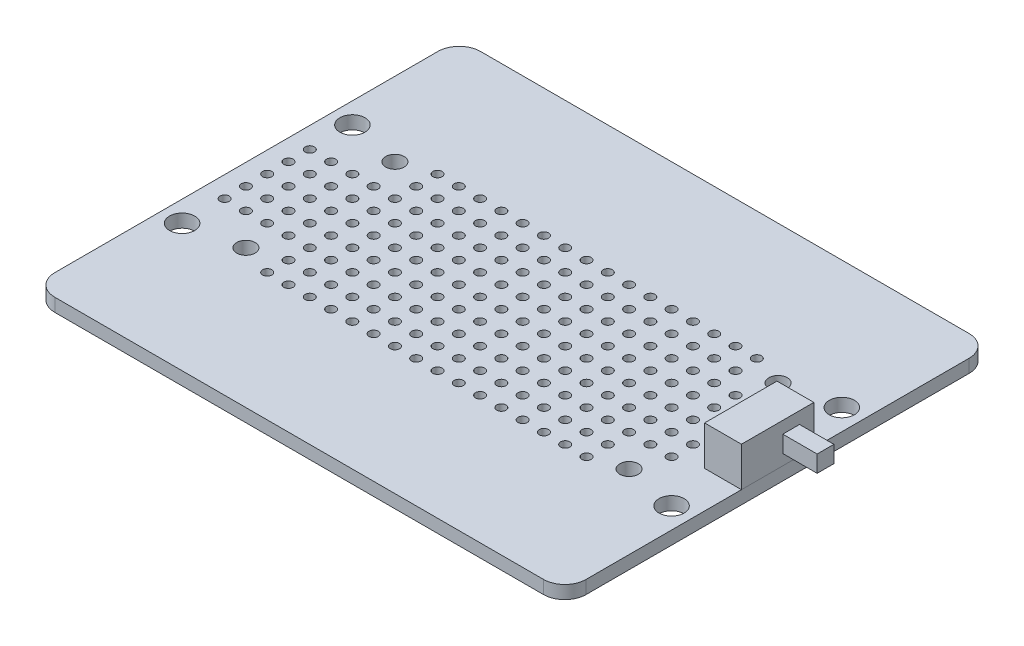
from build123d import *

# Parameters (mm, degrees)
SKETCH1_W           = 63.4
SKETCH1_H           = 50.8
SKETCH1_R           = 1.5
SKETCH1_R_2         = 1.1
BOSS_EXTRUDE1_DEPTH = 1.57
SKETCH9_R           = 0.55
CUT_EXTRUDE1_DEPTH  = 2.57
SKETCH7_W           = 4.4
SKETCH7_H           = 8.64
BOSS_EXTRUDE6_DEPTH = 4.7
SKETCH8_W           = 2
SKETCH8_H           = 2
BOSS_EXTRUDE7_DEPTH = 4.1
FILLET1_R           = 2.54


with BuildPart() as part:
    # Sketch1 → Boss-Extrude1 (new body)
    with BuildSketch(Plane(origin=(0, 0, 0), x_dir=(1, 0, 0), z_dir=(0, 1, 0))):
        Rectangle(SKETCH1_W, SKETCH1_H)
        with Locations((29.2, 10.16)):
            Circle(SKETCH1_R, mode=Mode.SUBTRACT)
        with Locations((29.2, -10.16)):
            Circle(SKETCH1_R, mode=Mode.SUBTRACT)
        with Locations((-29.2, 10.16)):
            Circle(SKETCH1_R, mode=Mode.SUBTRACT)
        with Locations((-29.2, -10.16)):
            Circle(SKETCH1_R, mode=Mode.SUBTRACT)
        with Locations((-22.86, 8.89)):
            Circle(SKETCH1_R_2, mode=Mode.SUBTRACT)
        with Locations((-22.86, -8.89)):
            Circle(SKETCH1_R_2, mode=Mode.SUBTRACT)
        with Locations((22.86, -8.89)):
            Circle(SKETCH1_R_2, mode=Mode.SUBTRACT)
        with Locations((22.86, 8.89)):
            Circle(SKETCH1_R_2, mode=Mode.SUBTRACT)
    extrude(amount=BOSS_EXTRUDE1_DEPTH)

    # Sketch9 → Cut-Extrude1 (cut, through all)
    with BuildSketch(Plane(origin=(0, 0, 0), x_dir=(1, 0, 0), z_dir=(0, 1, 0))):
        with Locations((-29.21, 10.16)):
            Circle(SKETCH9_R)
        with Locations((-19.05, 10.16)):
            Circle(SKETCH9_R)
        with Locations((-16.51, 10.16)):
            Circle(SKETCH9_R)
        with Locations((-13.97, 10.16)):
            Circle(SKETCH9_R)
        with Locations((-11.43, 10.16)):
            Circle(SKETCH9_R)
        with Locations((-8.89, 10.16)):
            Circle(SKETCH9_R)
        with Locations((-6.35, 10.16)):
            Circle(SKETCH9_R)
        with Locations((-3.81, 10.16)):
            Circle(SKETCH9_R)
        with Locations((-1.27, 10.16)):
            Circle(SKETCH9_R)
        with Locations((1.27, 10.16)):
            Circle(SKETCH9_R)
        with Locations((3.81, 10.16)):
            Circle(SKETCH9_R)
        with Locations((6.35, 10.16)):
            Circle(SKETCH9_R)
        with Locations((8.89, 10.16)):
            Circle(SKETCH9_R)
        with Locations((11.43, 10.16)):
            Circle(SKETCH9_R)
        with Locations((13.97, 10.16)):
            Circle(SKETCH9_R)
        with Locations((16.51, 10.16)):
            Circle(SKETCH9_R)
        with Locations((19.05, 10.16)):
            Circle(SKETCH9_R)
        with Locations((-19.05, 7.62)):
            Circle(SKETCH9_R)
        with Locations((-16.51, 7.62)):
            Circle(SKETCH9_R)
        with Locations((-13.97, 7.62)):
            Circle(SKETCH9_R)
        with Locations((-11.43, 7.62)):
            Circle(SKETCH9_R)
        with Locations((-8.89, 7.62)):
            Circle(SKETCH9_R)
        with Locations((-6.35, 7.62)):
            Circle(SKETCH9_R)
        with Locations((-3.81, 7.62)):
            Circle(SKETCH9_R)
        with Locations((-1.27, 7.62)):
            Circle(SKETCH9_R)
        with Locations((1.27, 7.62)):
            Circle(SKETCH9_R)
        with Locations((3.81, 7.62)):
            Circle(SKETCH9_R)
        with Locations((6.35, 7.62)):
            Circle(SKETCH9_R)
        with Locations((8.89, 7.62)):
            Circle(SKETCH9_R)
        with Locations((11.43, 7.62)):
            Circle(SKETCH9_R)
        with Locations((13.97, 7.62)):
            Circle(SKETCH9_R)
        with Locations((16.51, 7.62)):
            Circle(SKETCH9_R)
        with Locations((19.05, 7.62)):
            Circle(SKETCH9_R)
        with Locations((-26.67, 5.08)):
            Circle(SKETCH9_R)
        with Locations((-24.13, 5.08)):
            Circle(SKETCH9_R)
        with Locations((-21.59, 5.08)):
            Circle(SKETCH9_R)
        with Locations((-19.05, 5.08)):
            Circle(SKETCH9_R)
        with Locations((-16.51, 5.08)):
            Circle(SKETCH9_R)
        with Locations((-13.97, 5.08)):
            Circle(SKETCH9_R)
        with Locations((-11.43, 5.08)):
            Circle(SKETCH9_R)
        with Locations((-8.89, 5.08)):
            Circle(SKETCH9_R)
        with Locations((-6.35, 5.08)):
            Circle(SKETCH9_R)
        with Locations((-3.81, 5.08)):
            Circle(SKETCH9_R)
        with Locations((-1.27, 5.08)):
            Circle(SKETCH9_R)
        with Locations((1.27, 5.08)):
            Circle(SKETCH9_R)
        with Locations((3.81, 5.08)):
            Circle(SKETCH9_R)
        with Locations((6.35, 5.08)):
            Circle(SKETCH9_R)
        with Locations((8.89, 5.08)):
            Circle(SKETCH9_R)
        with Locations((11.43, 5.08)):
            Circle(SKETCH9_R)
        with Locations((13.97, 5.08)):
            Circle(SKETCH9_R)
        with Locations((16.51, 5.08)):
            Circle(SKETCH9_R)
        with Locations((19.05, 5.08)):
            Circle(SKETCH9_R)
        with Locations((21.59, 5.08)):
            Circle(SKETCH9_R)
        with Locations((24.13, 5.08)):
            Circle(SKETCH9_R)
        with Locations((-26.67, 2.54)):
            Circle(SKETCH9_R)
        with Locations((-24.13, 2.54)):
            Circle(SKETCH9_R)
        with Locations((-21.59, 2.54)):
            Circle(SKETCH9_R)
        with Locations((-19.05, 2.54)):
            Circle(SKETCH9_R)
        with Locations((-16.51, 2.54)):
            Circle(SKETCH9_R)
        with Locations((-13.97, 2.54)):
            Circle(SKETCH9_R)
        with Locations((-11.43, 2.54)):
            Circle(SKETCH9_R)
        with Locations((-8.89, 2.54)):
            Circle(SKETCH9_R)
        with Locations((-6.35, 2.54)):
            Circle(SKETCH9_R)
        with Locations((-3.81, 2.54)):
            Circle(SKETCH9_R)
        with Locations((-1.27, 2.54)):
            Circle(SKETCH9_R)
        with Locations((1.27, 2.54)):
            Circle(SKETCH9_R)
        with Locations((3.81, 2.54)):
            Circle(SKETCH9_R)
        with Locations((6.35, 2.54)):
            Circle(SKETCH9_R)
        with Locations((8.89, 2.54)):
            Circle(SKETCH9_R)
        with Locations((11.43, 2.54)):
            Circle(SKETCH9_R)
        with Locations((13.97, 2.54)):
            Circle(SKETCH9_R)
        with Locations((16.51, 2.54)):
            Circle(SKETCH9_R)
        with Locations((19.05, 2.54)):
            Circle(SKETCH9_R)
        with Locations((21.59, 2.54)):
            Circle(SKETCH9_R)
        with Locations((24.13, 2.54)):
            Circle(SKETCH9_R)
        with Locations((-26.67, 0)):
            Circle(SKETCH9_R)
        with Locations((-24.13, 0)):
            Circle(SKETCH9_R)
        with Locations((-21.59, 0)):
            Circle(SKETCH9_R)
        with Locations((-19.05, 0)):
            Circle(SKETCH9_R)
        with Locations((-16.51, 0)):
            Circle(SKETCH9_R)
        with Locations((-13.97, 0)):
            Circle(SKETCH9_R)
        with Locations((-11.43, 0)):
            Circle(SKETCH9_R)
        with Locations((-8.89, 0)):
            Circle(SKETCH9_R)
        with Locations((-6.35, 0)):
            Circle(SKETCH9_R)
        with Locations((-3.81, 0)):
            Circle(SKETCH9_R)
        with Locations((-1.27, 0)):
            Circle(SKETCH9_R)
        with Locations((1.27, 0)):
            Circle(SKETCH9_R)
        with Locations((3.81, 0)):
            Circle(SKETCH9_R)
        with Locations((6.35, 0)):
            Circle(SKETCH9_R)
        with Locations((8.89, 0)):
            Circle(SKETCH9_R)
        with Locations((11.43, 0)):
            Circle(SKETCH9_R)
        with Locations((13.97, 0)):
            Circle(SKETCH9_R)
        with Locations((16.51, 0)):
            Circle(SKETCH9_R)
        with Locations((19.05, 0)):
            Circle(SKETCH9_R)
        with Locations((21.59, 0)):
            Circle(SKETCH9_R)
        with Locations((24.13, 0)):
            Circle(SKETCH9_R)
        with Locations((-26.67, -2.54)):
            Circle(SKETCH9_R)
        with Locations((-24.13, -2.54)):
            Circle(SKETCH9_R)
        with Locations((-21.59, -2.54)):
            Circle(SKETCH9_R)
        with Locations((-19.05, -2.54)):
            Circle(SKETCH9_R)
        with Locations((-16.51, -2.54)):
            Circle(SKETCH9_R)
        with Locations((-13.97, -2.54)):
            Circle(SKETCH9_R)
        with Locations((-11.43, -2.54)):
            Circle(SKETCH9_R)
        with Locations((-8.89, -2.54)):
            Circle(SKETCH9_R)
        with Locations((-6.35, -2.54)):
            Circle(SKETCH9_R)
        with Locations((-3.81, -2.54)):
            Circle(SKETCH9_R)
        with Locations((-1.27, -2.54)):
            Circle(SKETCH9_R)
        with Locations((1.27, -2.54)):
            Circle(SKETCH9_R)
        with Locations((3.81, -2.54)):
            Circle(SKETCH9_R)
        with Locations((6.35, -2.54)):
            Circle(SKETCH9_R)
        with Locations((8.89, -2.54)):
            Circle(SKETCH9_R)
        with Locations((11.43, -2.54)):
            Circle(SKETCH9_R)
        with Locations((13.97, -2.54)):
            Circle(SKETCH9_R)
        with Locations((16.51, -2.54)):
            Circle(SKETCH9_R)
        with Locations((19.05, -2.54)):
            Circle(SKETCH9_R)
        with Locations((21.59, -2.54)):
            Circle(SKETCH9_R)
        with Locations((24.13, -2.54)):
            Circle(SKETCH9_R)
        with Locations((-26.67, -5.08)):
            Circle(SKETCH9_R)
        with Locations((-24.13, -5.08)):
            Circle(SKETCH9_R)
        with Locations((-21.59, -5.08)):
            Circle(SKETCH9_R)
        with Locations((-19.05, -5.08)):
            Circle(SKETCH9_R)
        with Locations((-16.51, -5.08)):
            Circle(SKETCH9_R)
        with Locations((-13.97, -5.08)):
            Circle(SKETCH9_R)
        with Locations((-11.43, -5.08)):
            Circle(SKETCH9_R)
        with Locations((-8.89, -5.08)):
            Circle(SKETCH9_R)
        with Locations((-6.35, -5.08)):
            Circle(SKETCH9_R)
        with Locations((-3.81, -5.08)):
            Circle(SKETCH9_R)
        with Locations((-1.27, -5.08)):
            Circle(SKETCH9_R)
        with Locations((1.27, -5.08)):
            Circle(SKETCH9_R)
        with Locations((3.81, -5.08)):
            Circle(SKETCH9_R)
        with Locations((6.35, -5.08)):
            Circle(SKETCH9_R)
        with Locations((8.89, -5.08)):
            Circle(SKETCH9_R)
        with Locations((11.43, -5.08)):
            Circle(SKETCH9_R)
        with Locations((13.97, -5.08)):
            Circle(SKETCH9_R)
        with Locations((16.51, -5.08)):
            Circle(SKETCH9_R)
        with Locations((19.05, -5.08)):
            Circle(SKETCH9_R)
        with Locations((21.59, -5.08)):
            Circle(SKETCH9_R)
        with Locations((24.13, -5.08)):
            Circle(SKETCH9_R)
        with Locations((-19.05, -7.62)):
            Circle(SKETCH9_R)
        with Locations((-16.51, -7.62)):
            Circle(SKETCH9_R)
        with Locations((-13.97, -7.62)):
            Circle(SKETCH9_R)
        with Locations((-11.43, -7.62)):
            Circle(SKETCH9_R)
        with Locations((-8.89, -7.62)):
            Circle(SKETCH9_R)
        with Locations((-6.35, -7.62)):
            Circle(SKETCH9_R)
        with Locations((-3.81, -7.62)):
            Circle(SKETCH9_R)
        with Locations((-1.27, -7.62)):
            Circle(SKETCH9_R)
        with Locations((1.27, -7.62)):
            Circle(SKETCH9_R)
        with Locations((3.81, -7.62)):
            Circle(SKETCH9_R)
        with Locations((6.35, -7.62)):
            Circle(SKETCH9_R)
        with Locations((8.89, -7.62)):
            Circle(SKETCH9_R)
        with Locations((11.43, -7.62)):
            Circle(SKETCH9_R)
        with Locations((13.97, -7.62)):
            Circle(SKETCH9_R)
        with Locations((16.51, -7.62)):
            Circle(SKETCH9_R)
        with Locations((19.05, -7.62)):
            Circle(SKETCH9_R)
        with Locations((-19.05, -10.16)):
            Circle(SKETCH9_R)
        with Locations((-16.51, -10.16)):
            Circle(SKETCH9_R)
        with Locations((-13.97, -10.16)):
            Circle(SKETCH9_R)
        with Locations((-11.43, -10.16)):
            Circle(SKETCH9_R)
        with Locations((-8.89, -10.16)):
            Circle(SKETCH9_R)
        with Locations((-6.35, -10.16)):
            Circle(SKETCH9_R)
        with Locations((-3.81, -10.16)):
            Circle(SKETCH9_R)
        with Locations((-1.27, -10.16)):
            Circle(SKETCH9_R)
        with Locations((1.27, -10.16)):
            Circle(SKETCH9_R)
        with Locations((3.81, -10.16)):
            Circle(SKETCH9_R)
        with Locations((6.35, -10.16)):
            Circle(SKETCH9_R)
        with Locations((8.89, -10.16)):
            Circle(SKETCH9_R)
        with Locations((11.43, -10.16)):
            Circle(SKETCH9_R)
        with Locations((13.97, -10.16)):
            Circle(SKETCH9_R)
        with Locations((16.51, -10.16)):
            Circle(SKETCH9_R)
        with Locations((19.05, -10.16)):
            Circle(SKETCH9_R)
        with Locations((-29.21, 5.08)):
            Circle(SKETCH9_R)
        with Locations((-29.21, 2.54)):
            Circle(SKETCH9_R)
        with Locations((-29.21, 0)):
            Circle(SKETCH9_R)
        with Locations((-29.21, -2.54)):
            Circle(SKETCH9_R)
        with Locations((-29.21, -5.08)):
            Circle(SKETCH9_R)
    extrude(amount=CUT_EXTRUDE1_DEPTH, mode=Mode.SUBTRACT)

    # Fillet1
    fillet1_edges = [part.edges().sort_by_distance(p)[0] for p in [
        (31.7, 0.785, 25.4),
        (-31.7, 0.785, 25.4),
        (-31.7, 0.785, -25.4),
        (31.7, 0.785, -25.4),
    ]]
    fillet(fillet1_edges, radius=FILLET1_R)


with BuildPart() as body_2:
    # Sketch7 → Boss-Extrude6 (new body)
    with BuildSketch(Plane(origin=(0, 1.57, 0), x_dir=(1, 0, 0), z_dir=(0, 1, 0))):
        with Locations((29.5, 0)):
            Rectangle(SKETCH7_W, SKETCH7_H)
    extrude(amount=BOSS_EXTRUDE6_DEPTH)


with BuildPart() as body_3:
    # Sketch8 → Boss-Extrude7 (new body)
    with BuildSketch(Plane(origin=(31.7, 0, 0), x_dir=(0, 0, -1), z_dir=(1, 0, 0))):
        with Locations((1.610325024, 3.843028274)):
            Rectangle(SKETCH8_W, SKETCH8_H)
    extrude(amount=BOSS_EXTRUDE7_DEPTH)


solid = Compound([part.part, body_2.part, body_3.part])
